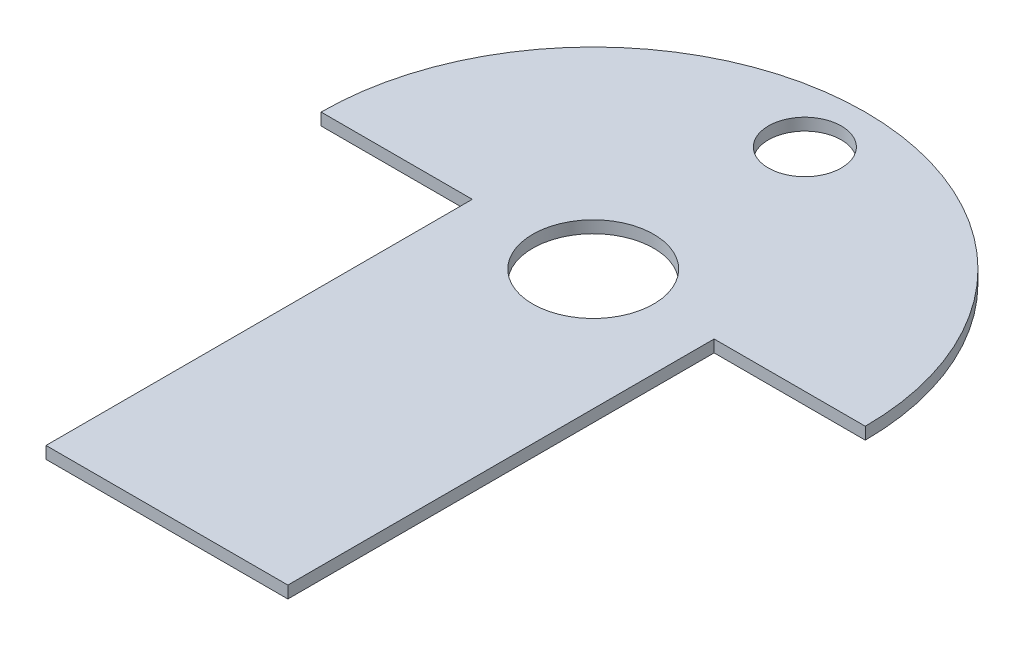
from build123d import *

# Parameters (mm, degrees)
ESQUISSE1_W             = 40
ESQUISSE1_H             = 70.5
BOSS_EXTRU_1_DEPTH      = 2
ESQUISSE2_R             = 10
ENL_V_MAT_EXTRU_1_DEPTH = 2
ESQUISSE3_R             = 6.03
ENL_V_MAT_EXTRU_2_DEPTH = 10


with BuildPart() as part:
    # Esquisse1 → Boss.-Extru.1 (new body)
    with BuildSketch(Plane(origin=(0, 0, 0), x_dir=(1, 0, 0), z_dir=(0, 1, 0))):
        with Locations((-5, 5.25)):
            Rectangle(ESQUISSE1_W, ESQUISSE1_H)
        with BuildLine():
            Line((-50, 40.5), (40, 40.5))
            ThreePointArc((40, 40.5), (-5, 85.5), (-50, 40.5))
        make_face()
    extrude(amount=BOSS_EXTRU_1_DEPTH)

    # Esquisse2 → Enlèv. mat.-Extru.1 (cut)
    with BuildSketch(Plane(origin=(0, 2, 0), x_dir=(1, 0, 0), z_dir=(0, 1, 0))):
        with Locations((-5, 40.5)):
            Circle(ESQUISSE2_R)
    extrude(amount=-ENL_V_MAT_EXTRU_1_DEPTH, mode=Mode.SUBTRACT)

    # Esquisse3 → Enlèv. mat.-Extru.2 (cut)
    with BuildSketch(Plane(origin=(0, 0, 0), x_dir=(-1, 0, 0), z_dir=(0, -1, 0))):
        with Locations((5, 75.5)):
            Circle(ESQUISSE3_R)
    extrude(amount=-ENL_V_MAT_EXTRU_2_DEPTH, mode=Mode.SUBTRACT)


solid = part.part
